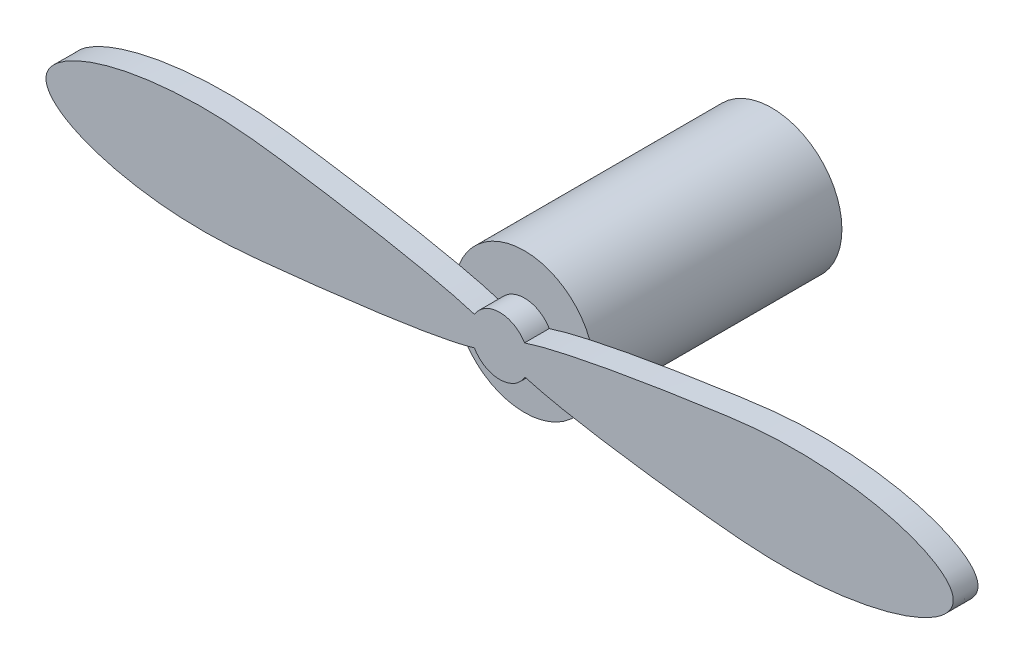
from build123d import *

# Parameters (mm, degrees)
SKETCH1_R           = 4.25
BOSS_EXTRUDE1_DEPTH = 15
BOSS_EXTRUDE2_DEPTH = 1.5


with BuildPart() as part:
    # Sketch1 → Boss-Extrude1 (new body)
    with BuildSketch(Plane.XY):
        Circle(SKETCH1_R)
    extrude(amount=BOSS_EXTRUDE1_DEPTH)

    # Sketch2 → Boss-Extrude2 (add)
    with BuildSketch(Plane.XY.offset(15)):
        with BuildLine():
            ThreePointArc((-1.533700981, -0.872101101), (0.000153071, -1.764312616), (1.533852284, -0.871834962))
            add(Edge.make_bspline(
                [(1.50837433, 0.915208125), (3.674043468, 1.615273216), (9.041308273, 2.555352687), (21.126434668, 4.242443839), (32.827619063, 0.448151773), (21.224545642, -3.554190079), (9.052186992, -2.328241324), (3.705331431, -1.518255924), (1.533852284, -0.871834962)],
                knots=[0.06989101, 0.06989101, 0.06989101, 0.06989101, 0.227812068, 0.270819598, 0.499966302, 0.730546414, 0.773598458, 0.930486743, 0.930486743, 0.930486743, 0.930486743], degree=3))
            ThreePointArc((1.50837433, 0.915208125), (-0.013837764, 1.764258356), (-1.522544538, 0.891435449))
            add(Edge.make_bspline(
                [(-1.522544538, 0.891435449), (-3.692002254, 1.57674274), (-9.054493456, 2.561553939), (-21.132416772, 4.237449152), (-32.489337553, 0.445121131), (-22.027907319, -3.542276517), (-10.001238176, -2.31393839), (-3.703611965, -1.518967575), (-1.533700981, -0.872101101)],
                knots=[0, 0, 0, 0, 0.157468993, 0.200426293, 0.429572998, 0.660153109, 0.703205382, 0.86009572, 0.86009572, 0.86009572, 0.86009572], degree=3))
        make_face()
    extrude(amount=BOSS_EXTRUDE2_DEPTH)


solid = part.part
